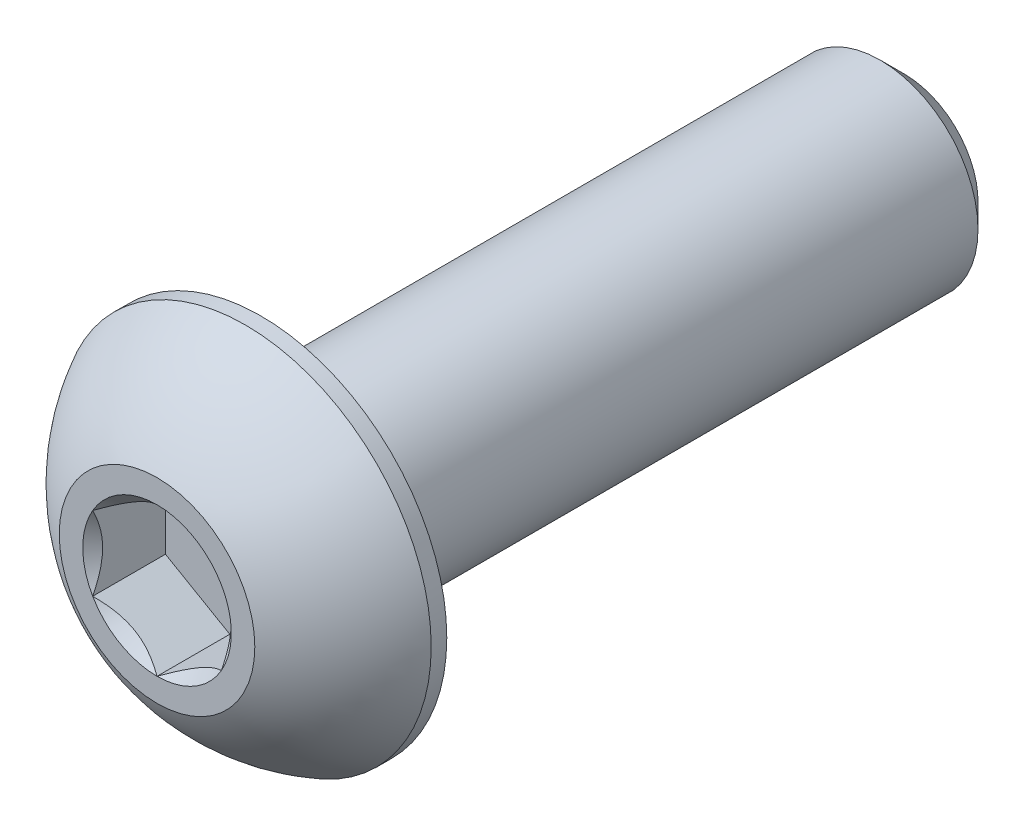
from build123d import *

# Parameters (mm, degrees)
SKETCH1_W          = 15.875
SKETCH1_H          = 2.413
CHAMFER1_SIZE      = 0.5953125
CUT_EXTRUDE2_DEPTH = 1.79578
SKETCH6_R          = 1.833087105
CUT_EXTRUDE3_DEPTH = 1.79578
CUT_EXTRUDE3_TAPER = 45


with BuildPart() as part:
    # Sketch1 → Revolve1 (revolve)
    with BuildSketch(Plane(origin=(0, 0, 0), x_dir=(0, 0, -1), z_dir=(1, 0, 0))):
        with Locations((10.5029, 1.2065)):
            Rectangle(SKETCH1_W, SKETCH1_H)
    revolve(axis=Axis((0, 0, -18.4404), (0, 0, 1)))

    # Chamfer1
    chamfer1_edges = [part.edges().sort_by_distance(p)[0] for p in [
        (0, -2.413, -18.4404),
    ]]
    chamfer(chamfer1_edges, length=CHAMFER1_SIZE)

    # Sketch7 → Revolve2 (revolve)
    with BuildSketch(Plane(origin=(0, 0, 0), x_dir=(0, 0, -1), z_dir=(1, 0, 0))):
        with BuildLine():
            Line((2.18059, 4.5847), (2.5654, 4.5847))
            Line((2.5654, 4.5847), (2.5654, 0))
            Line((2.5654, 0), (0, 0))
            Line((0, 0), (0, 2.413))
            ThreePointArc((0, 2.413), (0.925030326, 3.664791196), (2.18059, 4.5847))
        make_face()
    revolve(axis=Axis((0, 0, 0), (0, 0, -1)))

    # Sketch5 → Cut-Extrude2 (cut)
    with BuildSketch(Plane.XY):
        Polygon((1.5875, -0.916543552), (1.5875, 0.916543552), (0, 1.833087105), (-1.5875, 0.916543552), (-1.5875, -0.916543552), (0, -1.833087105), align=None)
    extrude(amount=-CUT_EXTRUDE2_DEPTH, mode=Mode.SUBTRACT)

    # Sketch6 → Cut-Extrude3 (cut)
    with BuildSketch(Plane.XY):
        Circle(SKETCH6_R)
    extrude(amount=-CUT_EXTRUDE3_DEPTH, taper=CUT_EXTRUDE3_TAPER, mode=Mode.SUBTRACT)


solid = part.part
